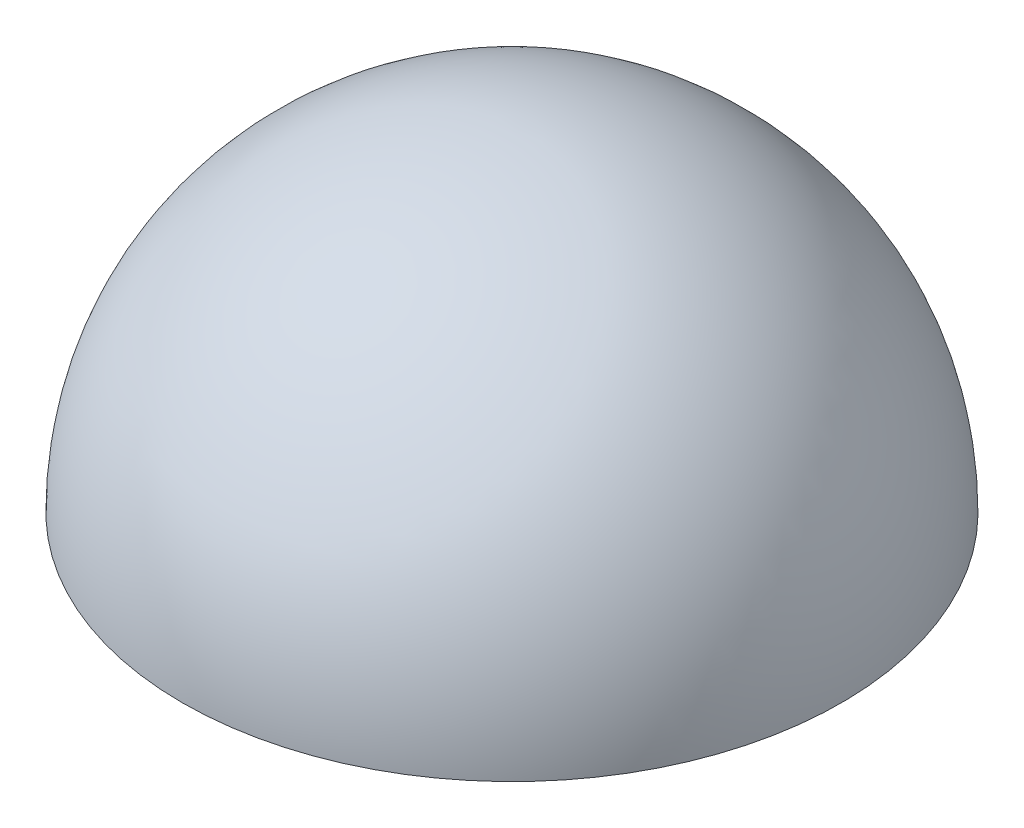
from build123d import *

# Parameters (mm, degrees)
REVOLVE1_ANGLE = 180


with BuildPart() as part:
    # Sketch1 → Revolve1 (revolve)
    with BuildSketch(Plane(origin=(0, 0, 0), x_dir=(1, 0, 0), z_dir=(0, 1, 0))):
        with BuildLine():
            Line((0, -4), (0, 4))
            ThreePointArc((0, 4), (-4, 0), (0, -4))
        make_face()
    revolve(axis=Axis((0, 0, 4), (0, 0, -1)), revolution_arc=REVOLVE1_ANGLE)


solid = part.part
